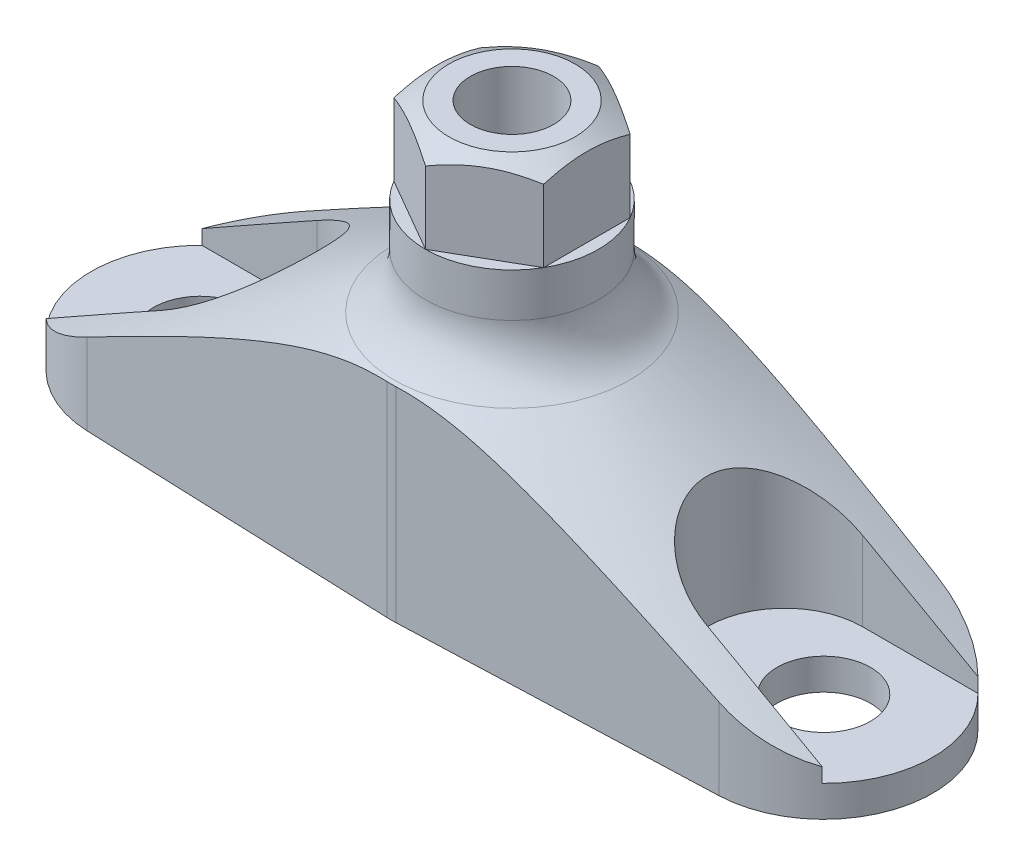
from build123d import *

# Parameters (mm, degrees)
SZKIC1_W                        = 27
SZKIC1_H                        = 25
ZAOKR_GLENIE1_R                 = 4
SZKIC4_R                        = 3
WYTNIJ_WYCI_GNI_CIE3_DEPTH      = 24.0000001
WYTNIJ_WYCI_GNI_CIE3_DEPTH_BACK = 3
WYTNIJ_WYCI_GNI_CIE2_DEPTH      = 24.0000001
SZKIC5_OUTSIDE_W                = 72.072
SZKIC5_OUTSIDE_H                = 72.072
WYTNIJ_WYCI_GNI_CIE4_DEPTH      = 26.0000001
SZKIC6_R                        = 2.675
WYTNIJ_WYCI_GNI_CIE5_DEPTH      = 26.0000001
SZKIC7_OUTSIDE_W                = 68.298
SZKIC7_OUTSIDE_H                = 29.798
WYTNIJ_WYCI_GNI_CIE6_DEPTH      = 5.5


with BuildPart() as part:
    # Szkic1 → Obrót1 (revolve)
    with BuildSketch(Plane.XY):
        with Locations((13.5, 12.5)):
            Rectangle(SZKIC1_W, SZKIC1_H)
    revolve(axis=Axis((0, 0, 0), (0, 1, 0)))

    # Szkic2 → Wycięcie-obrót1 (revolve, cut)
    with BuildSketch(Plane.XY):
        Polygon((5.55, 25), (5.55, 14.384163274), (27, 2), (27, 25), align=None)
    revolve(axis=Axis((0, 0, 0), (0, 1, 0)), mode=Mode.SUBTRACT)

    # Zaokrąglenie1
    zaokr_glenie1_edges = [part.edges().sort_by_distance(p)[0] for p in [
        (-5.55, 14.384163274, 0),
    ]]
    fillet(zaokr_glenie1_edges, radius=ZAOKR_GLENIE1_R)

    # Szkic4 → Wytnij-wyciągnięcie3 (cut, two sides)
    with BuildSketch(Plane(origin=(0, 2, 0), x_dir=(1, 0, 0), z_dir=(0, 1, 0))) as wytnij_wyci_gni_cie3_sk:
        with Locations((-20, 0)):
            Circle(SZKIC4_R)
        with Locations((20, 0)):
            Circle(SZKIC4_R)
    extrude(amount=WYTNIJ_WYCI_GNI_CIE3_DEPTH, mode=Mode.SUBTRACT)
    extrude(wytnij_wyci_gni_cie3_sk.sketch, amount=-WYTNIJ_WYCI_GNI_CIE3_DEPTH_BACK, mode=Mode.SUBTRACT)

    # Szkic3 → Wytnij-wyciągnięcie2 (cut, through all)
    with BuildSketch(Plane(origin=(0, 2, 0), x_dir=(1, 0, 0), z_dir=(0, 1, 0))):
        with BuildLine():
            Line((-17.5, 5), (-26.532998323, 5))
            ThreePointArc((-26.532998323, 5), (-27, 0), (-26.532998323, -5))
            Line((-26.532998323, -5), (-17.5, -5))
            ThreePointArc((-17.5, -5), (-12.5, 0), (-17.5, 5))
        make_face()
        with BuildLine():
            Line((17.5, 5), (26.532998323, 5))
            ThreePointArc((26.532998323, 5), (27, 0), (26.532998323, -5))
            Line((26.532998323, -5), (17.5, -5))
            ThreePointArc((17.5, -5), (12.5, 0), (17.5, 5))
        make_face()
    extrude(amount=WYTNIJ_WYCI_GNI_CIE2_DEPTH, mode=Mode.SUBTRACT)

    # Szkic5 outside → Wytnij-wyciągnięcie4 (cut, through all)
    with BuildSketch(Plane.XZ):
        Rectangle(SZKIC5_OUTSIDE_W, SZKIC5_OUTSIDE_H)
        with BuildLine():
            Line((-20.2625, 6.995076393), (-0.290625, 7.744548864))
            ThreePointArc((-0.290625, 7.744548864), (0, 7.75), (0.290625, 7.744548864))
            Line((0.290625, 7.744548864), (20.2625, 6.995076393))
            ThreePointArc((20.2625, 6.995076393), (27, 0), (20.2625, -6.995076393))
            Line((20.2625, -6.995076393), (0.290625, -7.744548864))
            ThreePointArc((0.290625, -7.744548864), (0, -7.75), (-0.290625, -7.744548864))
            Line((-0.290625, -7.744548864), (-20.2625, -6.995076393))
            ThreePointArc((-20.2625, -6.995076393), (-27, 0), (-20.2625, 6.995076393))
        make_face(mode=Mode.SUBTRACT)
    extrude(amount=-WYTNIJ_WYCI_GNI_CIE4_DEPTH, mode=Mode.SUBTRACT)

    # Szkic6 → Wytnij-wyciągnięcie5 (cut, through all)
    with BuildSketch(Plane(origin=(0, 25, 0), x_dir=(1, 0, 0), z_dir=(0, 1, 0))):
        Circle(SZKIC6_R)
    extrude(amount=-WYTNIJ_WYCI_GNI_CIE5_DEPTH, mode=Mode.SUBTRACT)

    # Szkic7 outside → Wytnij-wyciągnięcie6 (cut)
    with BuildSketch(Plane(origin=(0, 25, 0), x_dir=(1, 0, 0), z_dir=(0, 1, 0))):
        Rectangle(SZKIC7_OUTSIDE_W, SZKIC7_OUTSIDE_H)
        Polygon((-4.806440991, 2.775), (-4.806440991, -2.775), (0, -5.55), (4.806440991, -2.775), (4.806440991, 2.775), (0, 5.55), align=None, mode=Mode.SUBTRACT)
    extrude(amount=-WYTNIJ_WYCI_GNI_CIE6_DEPTH, mode=Mode.SUBTRACT)

    # Szkic9 → Wycięcie-obrót2 (revolve, cut)
    with BuildSketch(Plane.XY):
        Polygon((4.05, 25), (5.55, 24.133974596), (5.55, 25), align=None)
    revolve(axis=Axis((0, 19.5, 0), (0, 1, 0)), mode=Mode.SUBTRACT)


solid = part.part
